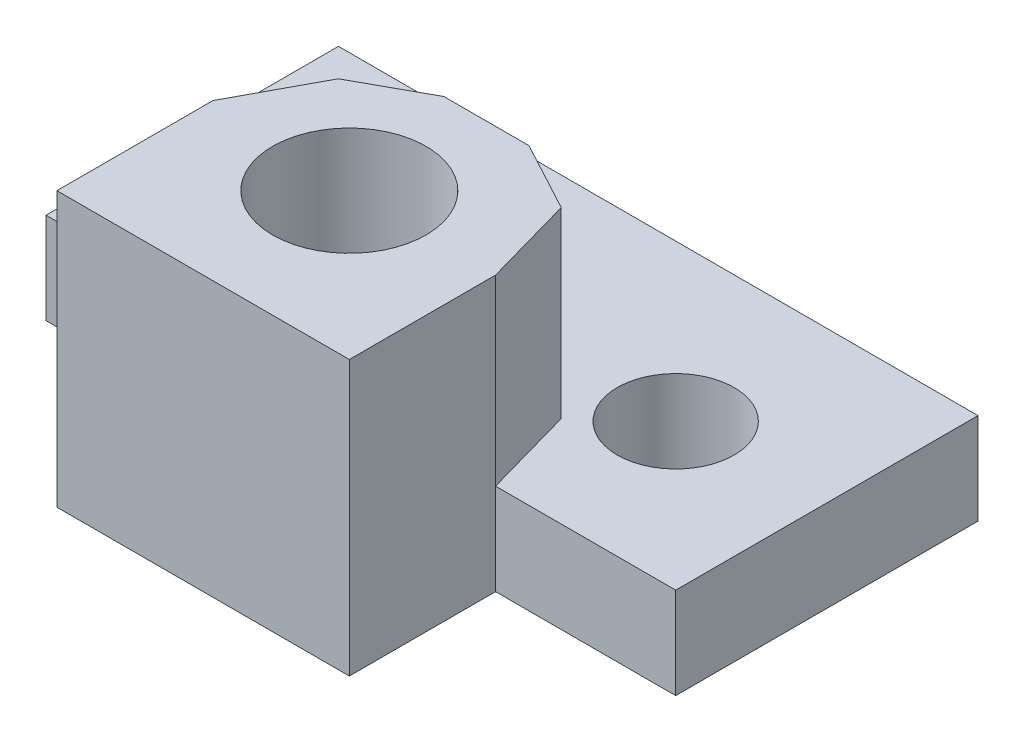
from build123d import *

# Parameters (mm, degrees)
SKETCH1_R           = 1.6
SKETCH1_R_2         = 2.5
BOSS_EXTRUDE1_DEPTH = 2.5
SKETCH3_R           = 2.1
BOSS_EXTRUDE2_DEPTH = 5


with BuildPart() as part:
    # Sketch1 → Boss-Extrude1 (new body)
    with BuildSketch(Plane(origin=(0, 0, 0), x_dir=(1, 0, 0), z_dir=(0, 1, 0))):
        Polygon((-8.568054712, 2.324906367), (-8.568054712, -5.675093633), (-4, -5.675093633), (-4, -9.944756554), (4, -9.944756554), (4, -5.944756554), (8.928117249, -5.944756554), (8.928117249, 2.324906367), align=None)
        with Locations((-4.568054712, -1.675093633)):
            Circle(SKETCH1_R, mode=Mode.SUBTRACT)
        with Locations((4.928117249, -1.944756554)):
            Circle(SKETCH1_R, mode=Mode.SUBTRACT)
        with Locations((0, -5.944756554)):
            Circle(SKETCH1_R_2, mode=Mode.SUBTRACT)
    extrude(amount=BOSS_EXTRUDE1_DEPTH)

    # Sketch3 → Boss-Extrude2 (add)
    with BuildSketch(Plane(origin=(0, 2.5, 0), x_dir=(1, 0, 0), z_dir=(0, 1, 0))):
        Polygon((4, -9.944756554), (-4, -9.944756554), (-4, -5.675093633), (-2.801852171, -3.446508049), (-0.938175021, -2.421485617), (1.391421416, -2.421485617), (3.297989337, -3.446508049), (4, -5.944756554), align=None)
        with Locations((0, -5.944756554)):
            Circle(SKETCH3_R, mode=Mode.SUBTRACT)
    extrude(amount=BOSS_EXTRUDE2_DEPTH)


solid = part.part
